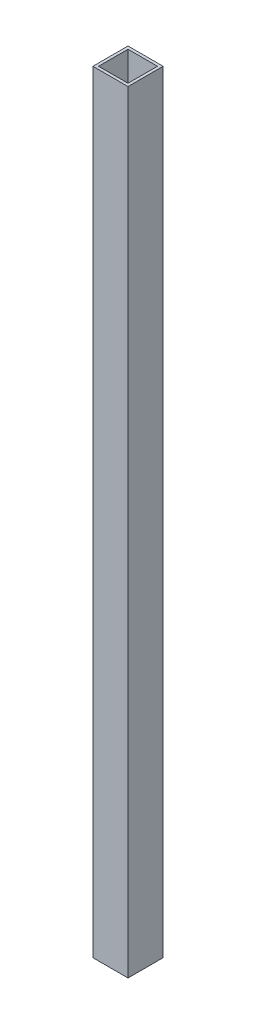
from build123d import *

# Parameters (mm, degrees)
SKETCH_1_W      = 25
SKETCH_1_H      = 25
SKETCH_1_W_2    = 21
SKETCH_1_H_2    = 21
EXTRUDE_1_DEPTH = 550


with BuildPart() as part:
    # Эскиз1 → Вытянуть-Тонкостенный1 (new body)
    with BuildSketch(Plane(origin=(0, 0, 0), x_dir=(1, 0, 0), z_dir=(0, 1, 0))):
        Rectangle(SKETCH_1_W, SKETCH_1_H)
        Rectangle(SKETCH_1_W_2, SKETCH_1_H_2, mode=Mode.SUBTRACT)
    extrude(amount=EXTRUDE_1_DEPTH)


solid = part.part
